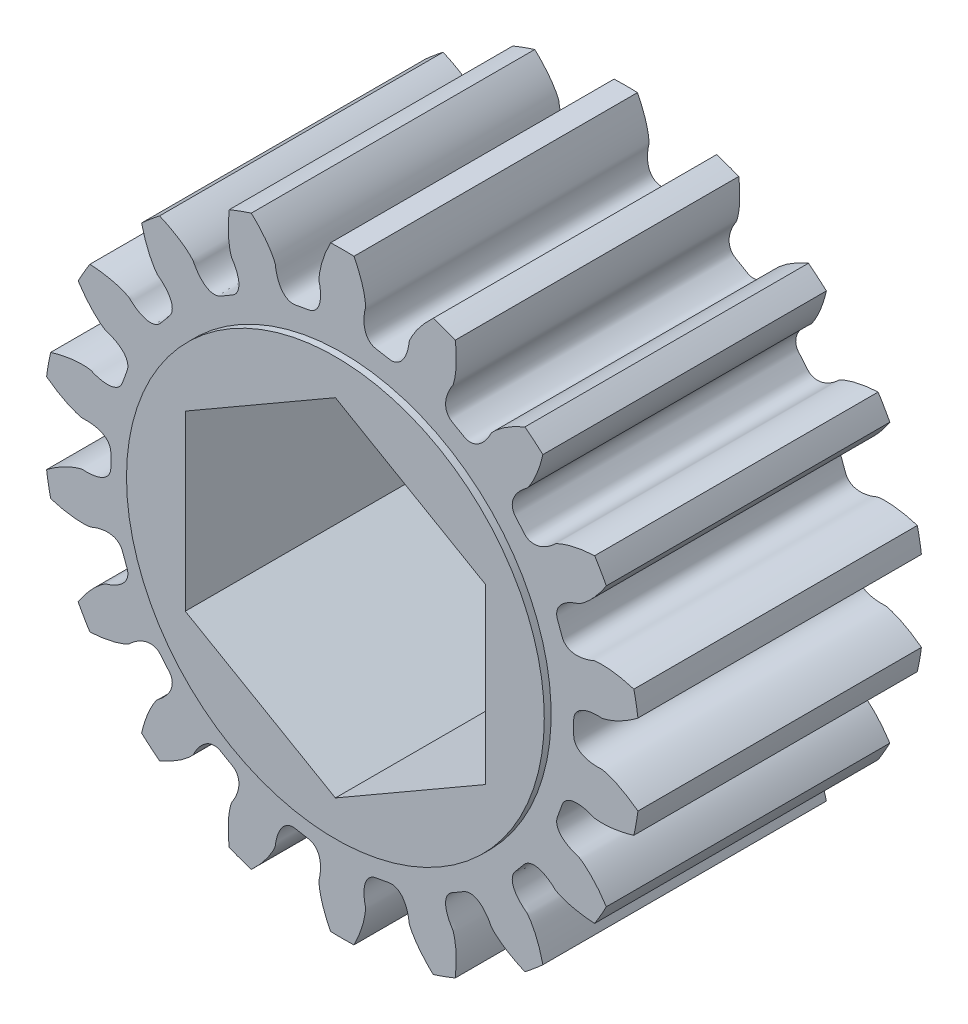
from build123d import *

# Parameters (mm, degrees)
BOSS_EXTRUDE1_DEPTH = 12.065
SKETCH2_R           = 8.89
BOSS_EXTRUDE2_DEPTH = 0.2921
SKETCH3_R           = 8.89
BOSS_EXTRUDE3_DEPTH = 0.2921
CUT_EXTRUDE1_DEPTH  = 13.6492


with BuildPart() as part:
    # Sketch1 → Boss-Extrude1 (new body)
    with BuildSketch(Plane.XY.offset(6.0325)):
        with BuildLine():
            ThreePointArc((12.410970883, -2.694030306), (12.507058369, -2.205331838), (12.583910389, -1.713241638))
            add(Edge.make_bspline(
                [(12.583910389, -1.713241638), (12.454495513, -1.615266365), (12.281691884, -1.494600081), (12.063530587, -1.360821083), (11.945634884, -1.293014345), (11.833605036, -1.232708673), (11.727763905, -1.179517154), (11.628417021, -1.133040061), (11.535852234, -1.09286743), (11.450339429, -1.058575143), (11.372129731, -1.029740178), (11.301456539, -1.005894736), (11.238530851, -0.986673766), (11.183554417, -0.971362731), (11.126066888, -0.957744243), (11.037383924, -0.935500863), (10.935383555, -0.952855993), (10.832757273, -0.948980949), (10.755684694, -0.945835715), (10.681454151, -0.939599556), (10.609986165, -0.931080188), (10.541241018, -0.920104184), (10.475144099, -0.906715101), (10.411601978, -0.890856967), (10.350496087, -0.872438809), (10.291684118, -0.851296022), (10.23500406, -0.827170041), (10.180287123, -0.799673241), (10.127386898, -0.768246797), (10.076238411, -0.732113156), (10.026966573, -0.690238537), (9.98006979, -0.641341891), (9.936675165, -0.584030203), (9.898843597, -0.517153755), (9.869552788, -0.440522263), (9.854050846, -0.362318712), (9.847049326, -0.214546824), (9.861767648, -5e-09), (9.847049326, 0.214546814), (9.854050846, 0.362318702), (9.869552789, 0.440522252), (9.898843597, 0.517153744), (9.936675165, 0.584030193), (9.980069791, 0.641341881), (10.026966574, 0.690238527), (10.076238412, 0.732113146), (10.127386899, 0.768246787), (10.180287124, 0.79967323), (10.235004061, 0.82717003), (10.291684119, 0.851296011), (10.350496088, 0.872438798), (10.411601979, 0.890856956), (10.4751441, 0.90671509), (10.541241019, 0.920104174), (10.609986166, 0.931080178), (10.681454152, 0.939599545), (10.755684695, 0.945835704), (10.832757274, 0.948980938), (10.935383556, 0.952855982), (11.037383925, 0.935500852), (11.126066889, 0.957744232), (11.183554418, 0.97136272), (11.238530852, 0.986673755), (11.30145654, 1.005894724), (11.372129732, 1.029740166), (11.45033943, 1.058575132), (11.535852235, 1.092867418), (11.628417022, 1.133040049), (11.727763907, 1.179517142), (11.833605037, 1.23270866), (11.945634885, 1.293014333), (12.063530588, 1.360821071), (12.281691885, 1.494600068), (12.454495515, 1.615266353), (12.58391039, 1.713241625)],
                knots=[0, 0, 0, 0, 0.068568258, 0.088954796, 0.108105787, 0.12602123, 0.142701125, 0.158145472, 0.172354272, 0.185327523, 0.197065227, 0.207567384, 0.216833992, 0.224865053, 0.231660567, 0.241835881, 0.263155637, 0.274398239, 0.285253325, 0.295735543, 0.30586243, 0.315655123, 0.325139277, 0.334346238, 0.343314557, 0.352091904, 0.360737466, 0.369324816, 0.377945084, 0.386709838, 0.395752205, 0.405223204, 0.415278018, 0.42604547, 0.437577809, 0.44979349, 0.459544035, 0.500000005, 0.540455975, 0.550206519, 0.5624222, 0.573954539, 0.584721991, 0.594776805, 0.604247805, 0.613290172, 0.622054925, 0.630675194, 0.639262544, 0.647908106, 0.656685453, 0.665653771, 0.674860733, 0.684344886, 0.69413758, 0.704264467, 0.714746685, 0.725601771, 0.736844372, 0.758164128, 0.768339443, 0.775134956, 0.783166017, 0.792432626, 0.802934782, 0.814672486, 0.827645738, 0.841854537, 0.857298885, 0.87397878, 0.891894222, 0.911045213, 0.931431751, 1.000000005, 1.000000005, 1.000000005, 1.000000005], degree=3))
            ThreePointArc((12.58391039, 1.713241625), (12.507058371, 2.205331832), (12.410970883, 2.694030306))
            add(Edge.make_bspline(
                [(12.410970883, 2.694030306), (12.255851163, 2.741834452), (12.052198568, 2.796121347), (11.801438895, 2.847216926), (11.667461903, 2.870611712), (11.541562526, 2.888964043), (11.423911826, 2.902747921), (11.31466019, 2.912443467), (11.213937893, 2.91853437), (11.121853489, 2.921511477), (11.038498274, 2.921858189), (10.963931576, 2.92009392), (10.898226812, 2.91663387), (10.84132918, 2.912218489), (10.782650776, 2.905353789), (10.691708366, 2.895924368), (10.601795176, 2.8447297), (10.504032672, 2.813270795), (10.430532405, 2.789865973), (10.35864562, 2.770337704), (10.288573885, 2.7538998), (10.220220564, 2.740701645), (10.153530441, 2.730676791), (10.088396577, 2.723845877), (10.024676441, 2.720253838), (9.962180009, 2.720006681), (9.900666605, 2.723291966), (9.839845043, 2.730416211), (9.779386616, 2.741854465), (9.718964327, 2.758315169), (9.658341981, 2.780812478), (9.597549782, 2.810720651), (9.537170421, 2.849734185), (9.478747284, 2.899638332), (9.425013413, 2.961630333), (9.383699162, 3.029815656), (9.326578923, 3.166281147), (9.267030288, 3.372923173), (9.179820255, 3.569497273), (9.13585857, 3.710752086), (9.123678441, 3.789541362), (9.124993284, 3.871569456), (9.137670236, 3.94735192), (9.158846094, 4.016049126), (9.186191017, 4.078036588), (9.218169437, 4.13423782), (9.253874859, 4.185686149), (9.292836333, 4.233310288), (9.334848976, 4.277863123), (9.379859237, 4.319919851), (9.427893151, 4.359902449), (9.479014525, 4.398109302), (9.533300786, 4.434743759), (9.590832237, 4.46993186), (9.651677529, 4.503758155), (9.715921673, 4.536207233), (9.783542674, 4.567455646), (9.854891475, 4.596771573), (9.950003292, 4.63551318), (10.05178809, 4.654090873), (10.127515133, 4.705324173), (10.176877942, 4.737783259), (10.223302209, 4.770973973), (10.275859055, 4.810557629), (10.33411451, 4.85713667), (10.397745447, 4.910981967), (10.466372546, 4.972453278), (10.539615145, 5.041862224), (10.617074577, 5.119515041), (10.698340136, 5.205698517), (10.782988003, 5.300683777), (10.870582454, 5.404723974), (11.029831903, 5.605050669), (11.150943898, 5.777542208), (11.239044585, 5.913871343)],
                knots=[0, 0, 0, 0, 0.068568258, 0.088954796, 0.108105787, 0.12602123, 0.142701125, 0.158145472, 0.172354272, 0.185327523, 0.197065227, 0.207567384, 0.216833992, 0.224865053, 0.231660567, 0.241835881, 0.263155637, 0.274398239, 0.285253325, 0.295735543, 0.30586243, 0.315655123, 0.325139277, 0.334346238, 0.343314557, 0.352091904, 0.360737466, 0.369324816, 0.377945084, 0.386709838, 0.395752205, 0.405223204, 0.415278018, 0.42604547, 0.437577809, 0.44979349, 0.459544035, 0.500000005, 0.540455975, 0.550206519, 0.5624222, 0.573954539, 0.584721991, 0.594776805, 0.604247805, 0.613290172, 0.622054925, 0.630675194, 0.639262544, 0.647908106, 0.656685453, 0.665653771, 0.674860733, 0.684344886, 0.69413758, 0.704264467, 0.714746685, 0.725601771, 0.736844372, 0.758164128, 0.768339443, 0.775134956, 0.783166017, 0.792432626, 0.802934782, 0.814672486, 0.827645738, 0.841854537, 0.857298885, 0.87397878, 0.891894222, 0.911045213, 0.931431751, 1.000000005, 1.000000005, 1.000000005, 1.000000005], degree=3))
            ThreePointArc((11.239044585, 5.913871343), (10.998522549, 6.349999934), (10.741085127, 6.776362423))
            add(Edge.make_bspline(
                [(10.741085127, 6.776362423), (10.57897029, 6.768229557), (10.369032237, 6.749589262), (10.115919506, 6.711838541), (9.982020827, 6.687999619), (9.857437245, 6.662185046), (9.742167386, 6.634898745), (9.636188358, 6.606643318), (9.539457148, 6.57791784), (9.451907882, 6.549220684), (9.373461019, 6.521037324), (9.303994658, 6.493876141), (9.243435784, 6.468152405), (9.191479648, 6.444543168), (9.138687851, 6.418023263), (9.05645499, 6.378058371), (8.989473837, 6.299198996), (8.908366713, 6.23620055), (8.847303975, 6.189068639), (8.786431555, 6.146131341), (8.726207757, 6.106718819), (8.66649068, 6.070938398), (8.607251166, 6.03870875), (8.548381665, 6.010012697), (8.489732872, 5.984843715), (8.431089969, 5.963236424), (8.372162644, 5.945284759), (8.312572436, 5.931177161), (8.251847984, 5.921247604), (8.189439713, 5.916049966), (8.124778809, 5.916456458), (8.057423631, 5.92376879), (7.987342176, 5.939778563), (7.915374162, 5.966691232), (7.843678327, 6.006566591), (7.781534876, 6.05650953), (7.681185462, 6.165208873), (7.554552314, 6.339022027), (7.405369388, 6.49391367), (7.315746925, 6.611613994), (7.277353829, 6.681485846), (7.250534116, 6.759016743), (7.236527426, 6.834564738), (7.232930395, 6.906361566), (7.237425257, 6.97396324), (7.248253188, 7.037712387), (7.264208945, 7.098269976), (7.28453234, 7.156347637), (7.308773343, 7.212582777), (7.336684905, 7.26749759), (7.368147166, 7.321497509), (7.40311803, 7.374884747), (7.441600707, 7.42787687), (7.483627548, 7.480619784), (7.529234146, 7.533216419), (7.578505655, 7.58568137), (7.631361024, 7.638173018), (7.688380328, 7.690123705), (7.764505791, 7.759059064), (7.85379827, 7.811328837), (7.907435592, 7.885372565), (7.942719799, 7.932757203), (7.974992447, 7.979824307), (8.010841319, 8.034996277), (8.04965257, 8.098690797), (8.091029917, 8.171051887), (8.134493868, 8.252287874), (8.17958014, 8.342561393), (8.225809369, 8.442023858), (8.27269753, 8.550804293), (8.319753634, 8.669012516), (8.36648165, 8.796737388), (8.447611417, 9.039449425), (8.502423885, 9.242961193), (8.53858414, 9.401200885)],
                knots=[0, 0, 0, 0, 0.068568258, 0.088954796, 0.108105787, 0.12602123, 0.142701125, 0.158145472, 0.172354272, 0.185327523, 0.197065227, 0.207567384, 0.216833992, 0.224865053, 0.231660567, 0.241835881, 0.263155637, 0.274398239, 0.285253325, 0.295735543, 0.30586243, 0.315655123, 0.325139277, 0.334346238, 0.343314557, 0.352091904, 0.360737466, 0.369324816, 0.377945084, 0.386709838, 0.395752205, 0.405223204, 0.415278018, 0.42604547, 0.437577809, 0.44979349, 0.459544035, 0.500000005, 0.540455975, 0.550206519, 0.5624222, 0.573954539, 0.584721991, 0.594776805, 0.604247805, 0.613290172, 0.622054925, 0.630675194, 0.639262544, 0.647908106, 0.656685453, 0.665653771, 0.674860733, 0.684344886, 0.69413758, 0.704264467, 0.714746685, 0.725601771, 0.736844372, 0.758164128, 0.768339443, 0.775134956, 0.783166017, 0.792432626, 0.802934782, 0.814672486, 0.827645738, 0.841854537, 0.857298885, 0.87397878, 0.891894222, 0.911045213, 0.931431751, 1.000000005, 1.000000005, 1.000000005, 1.000000005], degree=3))
            ThreePointArc((8.53858414, 9.401200885), (8.163402594, 9.728764322), (7.775665989, 10.041365223))
            add(Edge.make_bspline(
                [(7.775665989, 10.041365223), (7.626109477, 9.978276289), (7.435207594, 9.888957098), (7.210270936, 9.766913371), (7.092600726, 9.698716067), (6.984359558, 9.631848209), (6.885373786, 9.56678286), (6.795450001, 9.503984481), (6.714377089, 9.443907339), (6.641922695, 9.386997221), (6.577846033, 9.333683118), (6.521858679, 9.28440106), (6.473749987, 9.2395163), (6.433002025, 9.199560829), (6.392464304, 9.156584413), (6.32885949, 9.090904403), (6.292889289, 8.993891927), (6.238220261, 8.906952482), (6.196960119, 8.841778287), (6.154444176, 8.780610831), (6.111332194, 8.722977423), (6.067454122, 8.668930382), (6.022810376, 8.618383312), (5.977305769, 8.571283288), (5.93080223, 8.527573113), (5.883086055, 8.487211847), (5.833852314, 8.450188467), (5.782680918, 8.41655061), (5.729014708, 8.386450893), (5.672147813, 8.360221825), (5.61124741, 8.338488471), (5.545453281, 8.322322988), (5.47412259, 8.313397984), (5.397290103, 8.31407311), (5.31627988, 8.327022271), (5.240802647, 8.352698971), (5.109327678, 8.42052142), (4.930883844, 8.54054127), (4.737721687, 8.635068239), (4.613248238, 8.715017677), (4.553272948, 8.767544528), (4.501553533, 8.831226859), (4.462552614, 8.897428182), (4.434616549, 8.963664873), (4.415719203, 9.028727002), (4.404090638, 9.092334975), (4.39837223, 9.154697685), (4.397606244, 9.216223845), (4.401151785, 9.277358502), (4.408598102, 9.338507863), (4.419693896, 9.400011916), (4.434296249, 9.462140249), (4.452333762, 9.525098407), (4.473786935, 9.58903456), (4.49865401, 9.654057605), (4.527010014, 9.720210381), (4.558724614, 9.787613996), (4.594537051, 9.855933424), (4.642494306, 9.946747914), (4.708524474, 10.02640526), (4.733602623, 10.114328649), (4.750552431, 10.170923554), (4.764780903, 10.22619006), (4.779597899, 10.290295789), (4.794283736, 10.363423289), (4.808416773, 10.445572357), (4.821475183, 10.536774762), (4.832967058, 10.637024535), (4.842390157, 10.746300007), (4.849245516, 10.864556874), (4.853034196, 10.991730405), (4.853259689, 11.127734447), (4.846484327, 11.383557171), (4.828386074, 11.593542647), (4.808244437, 11.754606853)],
                knots=[0, 0, 0, 0, 0.068568258, 0.088954796, 0.108105787, 0.12602123, 0.142701125, 0.158145472, 0.172354272, 0.185327523, 0.197065227, 0.207567384, 0.216833992, 0.224865053, 0.231660567, 0.241835881, 0.263155637, 0.274398239, 0.285253325, 0.295735543, 0.30586243, 0.315655123, 0.325139277, 0.334346238, 0.343314557, 0.352091904, 0.360737466, 0.369324816, 0.377945084, 0.386709838, 0.395752205, 0.405223204, 0.415278018, 0.42604547, 0.437577809, 0.44979349, 0.459544035, 0.500000005, 0.540455975, 0.550206519, 0.5624222, 0.573954539, 0.584721991, 0.594776805, 0.604247805, 0.613290172, 0.622054925, 0.630675194, 0.639262544, 0.647908106, 0.656685453, 0.665653771, 0.674860733, 0.684344886, 0.69413758, 0.704264467, 0.714746685, 0.725601771, 0.736844372, 0.758164128, 0.768339443, 0.775134956, 0.783166017, 0.792432626, 0.802934782, 0.814672486, 0.827645738, 0.841854537, 0.857298885, 0.87397878, 0.891894222, 0.911045213, 0.931431751, 1.000000005, 1.000000005, 1.000000005, 1.000000005], degree=3))
            ThreePointArc((4.808244437, 11.754606853), (4.343655813, 11.934096152), (3.872386782, 12.095231182))
            add(Edge.make_bspline(
                [(3.872386782, 12.095231182), (3.753427317, 11.984795637), (3.604587189, 11.835570763), (3.434957284, 11.643954305), (3.347708308, 11.53962422), (3.268865036, 11.439768327), (3.198102496, 11.344771771), (3.13508009, 11.255004851), (3.079444065, 11.170822235), (3.030823612, 11.092563355), (2.988845743, 11.020548977), (2.953090296, 10.955090188), (2.923234405, 10.896458169), (2.898609422, 10.844975684), (2.875215224, 10.790726345), (2.837910136, 10.707253197), (2.837289425, 10.603788756), (2.815652384, 10.503394492), (2.799171421, 10.428038982), (2.780140005, 10.356019066), (2.75933978, 10.287116212), (2.736593057, 10.221321422), (2.711929774, 10.158553653), (2.685278587, 10.098730616), (2.656529316, 10.04175134), (2.625495144, 9.987504263), (2.591893302, 9.935874735), (2.555312744, 9.886763841), (2.515177711, 9.840124434), (2.47071118, 9.796027549), (2.420916765, 9.754775711), (2.364619428, 9.717082209), (2.300643036, 9.684298916), (2.228213209, 9.658655068), (2.147659626, 9.643116171), (2.067952278, 9.641429642), (1.921209576, 9.66019481), (1.712478015, 9.711945192), (1.498634835, 9.734706138), (1.354323736, 9.767261608), (1.280000156, 9.796107945), (1.209619164, 9.83826068), (1.150328102, 9.887130474), (1.101422505, 9.939817908), (1.06141225, 9.994493037), (1.028729765, 10.050287777), (1.002026917, 10.106933744), (0.980263939, 10.16448744), (0.962686374, 10.223147873), (0.948769309, 10.283156266), (0.93816032, 10.344746156), (0.930632902, 10.408121991), (0.926049662, 10.4734525), (0.924341599, 10.540870249), (0.925469814, 10.610476965), (0.92949016, 10.682338565), (0.936238741, 10.756524276), (0.946524804, 10.832972114), (0.960529497, 10.934712167), (0.995333141, 11.032149235), (0.988827324, 11.123347427), (0.985398336, 11.182326417), (0.979866467, 11.239126369), (0.971864438, 11.30443376), (0.960653533, 11.378173985), (0.945837607, 11.460202641), (0.92691544, 11.550371108), (0.903426828, 11.648505532), (0.874907232, 11.754413776), (0.840902932, 11.867883553), (0.800967217, 11.988683386), (0.754662989, 12.116562504), (0.660799707, 12.35463992), (0.571973649, 12.545771754), (0.497959499, 12.690233755)],
                knots=[0, 0, 0, 0, 0.068568258, 0.088954796, 0.108105787, 0.12602123, 0.142701125, 0.158145472, 0.172354272, 0.185327523, 0.197065227, 0.207567384, 0.216833992, 0.224865053, 0.231660567, 0.241835881, 0.263155637, 0.274398239, 0.285253325, 0.295735543, 0.30586243, 0.315655123, 0.325139277, 0.334346238, 0.343314557, 0.352091904, 0.360737466, 0.369324816, 0.377945084, 0.386709838, 0.395752205, 0.405223204, 0.415278018, 0.42604547, 0.437577809, 0.44979349, 0.459544035, 0.500000005, 0.540455975, 0.550206519, 0.5624222, 0.573954539, 0.584721991, 0.594776805, 0.604247805, 0.613290172, 0.622054925, 0.630675194, 0.639262544, 0.647908106, 0.656685453, 0.665653771, 0.674860733, 0.684344886, 0.69413758, 0.704264467, 0.714746685, 0.725601771, 0.736844372, 0.758164128, 0.768339443, 0.775134956, 0.783166017, 0.792432626, 0.802934782, 0.814672486, 0.827645738, 0.841854537, 0.857298885, 0.87397878, 0.891894222, 0.911045213, 0.931431751, 1.000000005, 1.000000005, 1.000000005, 1.000000005], degree=3))
            ThreePointArc((0.497959499, 12.690233755), (4.2e-08, 12.699999857), (-0.497959416, 12.690233754))
            add(Edge.make_bspline(
                [(-0.497959416, 12.690233754), (-0.571973566, 12.545771754), (-0.660799623, 12.354639919), (-0.754662905, 12.116562503), (-0.800967133, 11.988683385), (-0.840902847, 11.867883552), (-0.874907148, 11.754413776), (-0.903426744, 11.648505531), (-0.926915355, 11.550371107), (-0.945837523, 11.46020264), (-0.960653449, 11.378173984), (-0.971864354, 11.304433759), (-0.979866382, 11.239126368), (-0.985398251, 11.182326416), (-0.988827239, 11.123347426), (-0.995333057, 11.032149233), (-0.960529412, 10.934712166), (-0.946524718, 10.832972113), (-0.936238656, 10.756524275), (-0.929490075, 10.682338564), (-0.925469729, 10.610476964), (-0.924341513, 10.540870248), (-0.926049577, 10.473452499), (-0.930632816, 10.40812199), (-0.938160235, 10.344746155), (-0.948769224, 10.283156265), (-0.962686288, 10.223147872), (-0.980263854, 10.164487439), (-1.002026831, 10.106933743), (-1.028729679, 10.050287776), (-1.061412164, 9.994493036), (-1.101422419, 9.939817907), (-1.150328016, 9.887130473), (-1.209619078, 9.838260679), (-1.28000007, 9.796107944), (-1.354323649, 9.767261607), (-1.498634749, 9.734706137), (-1.712477929, 9.71194519), (-1.92120949, 9.660194808), (-2.067952192, 9.64142964), (-2.147659539, 9.643116169), (-2.228213122, 9.658655066), (-2.30064295, 9.684298913), (-2.364619342, 9.717082207), (-2.420916679, 9.754775709), (-2.470711094, 9.796027546), (-2.515177625, 9.840124431), (-2.555312658, 9.886763838), (-2.591893216, 9.935874733), (-2.625495058, 9.987504261), (-2.65652923, 10.041751337), (-2.685278501, 10.098730613), (-2.711929688, 10.158553651), (-2.736592971, 10.221321419), (-2.759339694, 10.287116209), (-2.78013992, 10.356019063), (-2.799171336, 10.42803898), (-2.815652299, 10.503394489), (-2.837289339, 10.603788753), (-2.837910051, 10.707253194), (-2.875215139, 10.790726342), (-2.898609336, 10.844975681), (-2.92323432, 10.896458166), (-2.953090211, 10.955090185), (-2.988845658, 11.020548974), (-3.030823527, 11.092563352), (-3.07944398, 11.170822232), (-3.135080005, 11.255004848), (-3.198102412, 11.344771768), (-3.268864951, 11.439768323), (-3.347708224, 11.539624216), (-3.434957199, 11.643954302), (-3.604587105, 11.835570759), (-3.753427233, 11.984795633), (-3.872386698, 12.095231178)],
                knots=[0, 0, 0, 0, 0.068568258, 0.088954796, 0.108105787, 0.12602123, 0.142701125, 0.158145472, 0.172354272, 0.185327523, 0.197065227, 0.207567384, 0.216833992, 0.224865053, 0.231660567, 0.241835881, 0.263155637, 0.274398239, 0.285253325, 0.295735543, 0.30586243, 0.315655123, 0.325139277, 0.334346238, 0.343314557, 0.352091904, 0.360737466, 0.369324816, 0.377945084, 0.386709838, 0.395752205, 0.405223204, 0.415278018, 0.42604547, 0.437577809, 0.44979349, 0.459544035, 0.500000005, 0.540455975, 0.550206519, 0.5624222, 0.573954539, 0.584721991, 0.594776805, 0.604247805, 0.613290172, 0.622054925, 0.630675194, 0.639262544, 0.647908106, 0.656685453, 0.665653771, 0.674860733, 0.684344886, 0.69413758, 0.704264467, 0.714746685, 0.725601771, 0.736844372, 0.758164128, 0.768339443, 0.775134956, 0.783166017, 0.792432626, 0.802934782, 0.814672486, 0.827645738, 0.841854537, 0.857298885, 0.87397878, 0.891894222, 0.911045213, 0.931431751, 1.000000005, 1.000000005, 1.000000005, 1.000000005], degree=3))
            ThreePointArc((-3.872386698, 12.095231178), (-4.343655729, 11.934096147), (-4.808244353, 11.754606848))
            add(Edge.make_bspline(
                [(-4.808244353, 11.754606848), (-4.82838599, 11.593542642), (-4.846484243, 11.383557166), (-4.853259604, 11.127734442), (-4.853034111, 10.9917304), (-4.849245431, 10.864556869), (-4.842390072, 10.746300002), (-4.832966973, 10.63702453), (-4.821475098, 10.536774757), (-4.808416687, 10.445572352), (-4.794283651, 10.363423284), (-4.779597813, 10.290295784), (-4.764780817, 10.226190055), (-4.750552345, 10.170923549), (-4.733602538, 10.114328644), (-4.708524388, 10.026405255), (-4.64249422, 9.946747909), (-4.594536965, 9.855933419), (-4.558724527, 9.787613991), (-4.527009928, 9.720210376), (-4.498653924, 9.6540576), (-4.473786849, 9.589034555), (-4.452333676, 9.525098402), (-4.434296162, 9.462140244), (-4.419693809, 9.400011911), (-4.408598015, 9.338507859), (-4.401151699, 9.277358498), (-4.397606157, 9.21622384), (-4.398372143, 9.15469768), (-4.404090551, 9.092334971), (-4.415719116, 9.028726997), (-4.434616462, 8.963664869), (-4.462552527, 8.897428177), (-4.501553446, 8.831226854), (-4.553272861, 8.767544524), (-4.613248151, 8.715017672), (-4.7377216, 8.635068234), (-4.930883756, 8.540541265), (-5.109327591, 8.420521415), (-5.240802559, 8.352698965), (-5.316279792, 8.327022266), (-5.397290015, 8.314073104), (-5.474122503, 8.313397978), (-5.545453193, 8.322322982), (-5.611247322, 8.338488465), (-5.672147725, 8.360221819), (-5.72901462, 8.386450887), (-5.78268083, 8.416550604), (-5.833852226, 8.450188461), (-5.883085968, 8.487211841), (-5.930802143, 8.527573107), (-5.977305681, 8.571283282), (-6.022810289, 8.618383306), (-6.067454035, 8.668930375), (-6.111332106, 8.722977417), (-6.154444089, 8.780610824), (-6.196960032, 8.84177828), (-6.238220174, 8.906952475), (-6.292889201, 8.993891921), (-6.328859403, 9.090904397), (-6.392464217, 9.156584406), (-6.433001938, 9.199560823), (-6.4737499, 9.239516293), (-6.521858592, 9.284401053), (-6.577845946, 9.333683111), (-6.641922608, 9.386997214), (-6.714377002, 9.443907332), (-6.795449914, 9.503984474), (-6.8853737, 9.566782853), (-6.984359472, 9.631848201), (-7.09260064, 9.69871606), (-7.210270849, 9.766913364), (-7.435207508, 9.88895709), (-7.626109391, 9.978276281), (-7.775665903, 10.041365215)],
                knots=[0, 0, 0, 0, 0.068568258, 0.088954796, 0.108105787, 0.12602123, 0.142701125, 0.158145472, 0.172354272, 0.185327523, 0.197065227, 0.207567384, 0.216833992, 0.224865053, 0.231660567, 0.241835881, 0.263155637, 0.274398239, 0.285253325, 0.295735543, 0.30586243, 0.315655123, 0.325139277, 0.334346238, 0.343314557, 0.352091904, 0.360737466, 0.369324816, 0.377945084, 0.386709838, 0.395752205, 0.405223204, 0.415278018, 0.42604547, 0.437577809, 0.44979349, 0.459544035, 0.500000005, 0.540455975, 0.550206519, 0.5624222, 0.573954539, 0.584721991, 0.594776805, 0.604247805, 0.613290172, 0.622054925, 0.630675194, 0.639262544, 0.647908106, 0.656685453, 0.665653771, 0.674860733, 0.684344886, 0.69413758, 0.704264467, 0.714746685, 0.725601771, 0.736844372, 0.758164128, 0.768339443, 0.775134956, 0.783166017, 0.792432626, 0.802934782, 0.814672486, 0.827645738, 0.841854537, 0.857298885, 0.87397878, 0.891894222, 0.911045213, 0.931431751, 1.000000005, 1.000000005, 1.000000005, 1.000000005], degree=3))
            ThreePointArc((-7.775665903, 10.041365215), (-8.163402508, 9.728764314), (-8.538584053, 9.401200876))
            add(Edge.make_bspline(
                [(-8.538584053, 9.401200876), (-8.502423798, 9.242961184), (-8.44761133, 9.039449416), (-8.366481563, 8.79673738), (-8.319753546, 8.669012508), (-8.272697442, 8.550804284), (-8.225809282, 8.44202385), (-8.179580052, 8.342561384), (-8.13449378, 8.252287866), (-8.091029829, 8.171051878), (-8.049652482, 8.098690788), (-8.010841231, 8.034996268), (-7.974992359, 7.979824299), (-7.942719711, 7.932757195), (-7.907435504, 7.885372557), (-7.853798181, 7.811328829), (-7.764505703, 7.759059056), (-7.68838024, 7.690123697), (-7.631360936, 7.63817301), (-7.578505567, 7.585681362), (-7.529234057, 7.533216411), (-7.483627459, 7.480619776), (-7.441600618, 7.427876863), (-7.403117941, 7.374884739), (-7.368147077, 7.321497502), (-7.336684816, 7.267497582), (-7.308773254, 7.21258277), (-7.284532251, 7.15634763), (-7.264208856, 7.098269968), (-7.248253099, 7.03771238), (-7.237425168, 6.973963233), (-7.232930305, 6.906361558), (-7.236527337, 6.834564731), (-7.250534027, 6.759016736), (-7.277353739, 6.681485838), (-7.315746836, 6.611613986), (-7.405369299, 6.493913663), (-7.554552225, 6.339022019), (-7.681185372, 6.165208865), (-7.781534786, 6.056509522), (-7.843678237, 6.006566583), (-7.915374072, 5.966691223), (-7.987342086, 5.939778555), (-8.057423541, 5.923768782), (-8.124778719, 5.916456449), (-8.189439623, 5.916049957), (-8.251847894, 5.921247596), (-8.312572346, 5.931177152), (-8.372162554, 5.94528475), (-8.431089879, 5.963236416), (-8.489732782, 5.984843706), (-8.548381574, 6.010012688), (-8.607251076, 6.038708741), (-8.66649059, 6.070938389), (-8.726207667, 6.10671881), (-8.786431465, 6.146131332), (-8.847303885, 6.18906863), (-8.908366623, 6.236200541), (-8.989473747, 6.299198987), (-9.056454901, 6.378058361), (-9.138687761, 6.418023254), (-9.191479559, 6.444543158), (-9.243435694, 6.468152395), (-9.303994569, 6.493876131), (-9.373460929, 6.521037315), (-9.451907792, 6.549220675), (-9.539457058, 6.57791783), (-9.636188269, 6.606643308), (-9.742167297, 6.634898735), (-9.857437156, 6.662185035), (-9.982020738, 6.687999609), (-10.115919417, 6.71183853), (-10.369032148, 6.749589251), (-10.578970201, 6.768229546), (-10.741085038, 6.776362412)],
                knots=[0, 0, 0, 0, 0.068568258, 0.088954796, 0.108105787, 0.12602123, 0.142701125, 0.158145472, 0.172354272, 0.185327523, 0.197065227, 0.207567384, 0.216833992, 0.224865053, 0.231660567, 0.241835881, 0.263155637, 0.274398239, 0.285253325, 0.295735543, 0.30586243, 0.315655123, 0.325139277, 0.334346238, 0.343314557, 0.352091904, 0.360737466, 0.369324816, 0.377945084, 0.386709838, 0.395752205, 0.405223204, 0.415278018, 0.42604547, 0.437577809, 0.44979349, 0.459544035, 0.500000005, 0.540455975, 0.550206519, 0.5624222, 0.573954539, 0.584721991, 0.594776805, 0.604247805, 0.613290172, 0.622054925, 0.630675194, 0.639262544, 0.647908106, 0.656685453, 0.665653771, 0.674860733, 0.684344886, 0.69413758, 0.704264467, 0.714746685, 0.725601771, 0.736844372, 0.758164128, 0.768339443, 0.775134956, 0.783166017, 0.792432626, 0.802934782, 0.814672486, 0.827645738, 0.841854537, 0.857298885, 0.87397878, 0.891894222, 0.911045213, 0.931431751, 1.000000005, 1.000000005, 1.000000005, 1.000000005], degree=3))
            ThreePointArc((-10.741085038, 6.776362412), (-10.998522459, 6.349999923), (-11.239044495, 5.913871331))
            add(Edge.make_bspline(
                [(-11.239044495, 5.913871331), (-11.150943808, 5.777542197), (-11.029831812, 5.605050658), (-10.870582363, 5.404723963), (-10.782987912, 5.300683766), (-10.698340045, 5.205698506), (-10.617074486, 5.11951503), (-10.539615054, 5.041862213), (-10.466372455, 4.972453267), (-10.397745356, 4.910981956), (-10.334114419, 4.85713666), (-10.275858964, 4.810557619), (-10.223302118, 4.770973963), (-10.176877851, 4.737783248), (-10.127515041, 4.705324163), (-10.051787999, 4.654090863), (-9.950003201, 4.635513169), (-9.854891383, 4.596771563), (-9.783542583, 4.567455636), (-9.715921582, 4.536207223), (-9.651677437, 4.503758145), (-9.590832145, 4.46993185), (-9.533300694, 4.434743749), (-9.479014433, 4.398109293), (-9.427893059, 4.35990244), (-9.379859145, 4.319919841), (-9.334848884, 4.277863113), (-9.292836241, 4.233310278), (-9.253874767, 4.185686139), (-9.218169345, 4.13423781), (-9.186190925, 4.078036578), (-9.158846002, 4.016049116), (-9.137670144, 3.94735191), (-9.124993192, 3.871569447), (-9.123678349, 3.789541353), (-9.135858477, 3.710752077), (-9.179820163, 3.569497263), (-9.267030195, 3.372923163), (-9.32657883, 3.166281138), (-9.383699069, 3.029815646), (-9.42501332, 2.961630323), (-9.47874719, 2.899638322), (-9.537170328, 2.849734175), (-9.597549689, 2.810720641), (-9.658341887, 2.780812468), (-9.718964234, 2.758315159), (-9.779386522, 2.741854455), (-9.83984495, 2.730416201), (-9.900666511, 2.723291955), (-9.962179915, 2.720006671), (-10.024676347, 2.720253828), (-10.088396483, 2.723845866), (-10.153530347, 2.73067678), (-10.220220471, 2.740701635), (-10.288573792, 2.75389979), (-10.358645527, 2.770337694), (-10.430532312, 2.789865962), (-10.504032579, 2.813270784), (-10.601795082, 2.844729689), (-10.691708273, 2.895924358), (-10.782650683, 2.905353778), (-10.841329087, 2.912218478), (-10.898226719, 2.916633859), (-10.963931482, 2.920093908), (-11.03849818, 2.921858178), (-11.121853396, 2.921511465), (-11.2139378, 2.918534358), (-11.314660097, 2.912443455), (-11.423911733, 2.90274791), (-11.541562433, 2.888964031), (-11.667461809, 2.8706117), (-11.801438801, 2.847216914), (-12.052198474, 2.796121335), (-12.25585107, 2.74183444), (-12.41097079, 2.694030294)],
                knots=[0, 0, 0, 0, 0.068568258, 0.088954796, 0.108105787, 0.12602123, 0.142701125, 0.158145472, 0.172354272, 0.185327523, 0.197065227, 0.207567384, 0.216833992, 0.224865053, 0.231660567, 0.241835881, 0.263155637, 0.274398239, 0.285253325, 0.295735543, 0.30586243, 0.315655123, 0.325139277, 0.334346238, 0.343314557, 0.352091904, 0.360737466, 0.369324816, 0.377945084, 0.386709838, 0.395752205, 0.405223204, 0.415278018, 0.42604547, 0.437577809, 0.44979349, 0.459544035, 0.500000005, 0.540455975, 0.550206519, 0.5624222, 0.573954539, 0.584721991, 0.594776805, 0.604247805, 0.613290172, 0.622054925, 0.630675194, 0.639262544, 0.647908106, 0.656685453, 0.665653771, 0.674860733, 0.684344886, 0.69413758, 0.704264467, 0.714746685, 0.725601771, 0.736844372, 0.758164128, 0.768339443, 0.775134956, 0.783166017, 0.792432626, 0.802934782, 0.814672486, 0.827645738, 0.841854537, 0.857298885, 0.87397878, 0.891894222, 0.911045213, 0.931431751, 1.000000005, 1.000000005, 1.000000005, 1.000000005], degree=3))
            ThreePointArc((-12.41097079, 2.694030294), (-12.507058275, 2.205331828), (-12.583910293, 1.713241631))
            add(Edge.make_bspline(
                [(-12.583910293, 1.713241631), (-12.454495418, 1.615266359), (-12.281691788, 1.494600075), (-12.063530491, 1.360821077), (-11.945634789, 1.293014339), (-11.83360494, 1.232708667), (-11.72776381, 1.179517148), (-11.628416925, 1.133040055), (-11.535852138, 1.092867424), (-11.450339333, 1.058575137), (-11.372129635, 1.029740172), (-11.301456443, 1.00589473), (-11.238530755, 0.986673761), (-11.183554321, 0.971362725), (-11.126066792, 0.957744237), (-11.037383829, 0.935500858), (-10.93538346, 0.952855987), (-10.832757177, 0.948980943), (-10.755684598, 0.94583571), (-10.681454055, 0.939599551), (-10.609986069, 0.931080183), (-10.541240923, 0.920104179), (-10.475144003, 0.906715096), (-10.411601882, 0.890856962), (-10.350495991, 0.872438803), (-10.291684022, 0.851296017), (-10.235003964, 0.827170036), (-10.180287027, 0.799673236), (-10.127386802, 0.768246792), (-10.076238316, 0.732113151), (-10.026966477, 0.690238532), (-9.980069694, 0.641341886), (-9.936675069, 0.584030198), (-9.898843501, 0.51715375), (-9.869552692, 0.440522258), (-9.85405075, 0.362318707), (-9.84704923, 0.214546819), (-9.861767552, 0), (-9.84704923, -0.214546819), (-9.85405075, -0.362318707), (-9.869552692, -0.440522258), (-9.898843501, -0.51715375), (-9.936675069, -0.584030198), (-9.980069694, -0.641341886), (-10.026966477, -0.690238532), (-10.076238316, -0.732113151), (-10.127386802, -0.768246792), (-10.180287027, -0.799673236), (-10.235003964, -0.827170036), (-10.291684022, -0.851296017), (-10.350495991, -0.872438803), (-10.411601882, -0.890856962), (-10.475144003, -0.906715096), (-10.541240923, -0.920104179), (-10.609986069, -0.931080183), (-10.681454055, -0.939599551), (-10.755684598, -0.94583571), (-10.832757177, -0.948980943), (-10.93538346, -0.952855987), (-11.037383829, -0.935500858), (-11.126066792, -0.957744237), (-11.183554321, -0.971362725), (-11.238530755, -0.986673761), (-11.301456443, -1.00589473), (-11.372129635, -1.029740172), (-11.450339333, -1.058575137), (-11.535852138, -1.092867424), (-11.628416925, -1.133040055), (-11.72776381, -1.179517148), (-11.83360494, -1.232708667), (-11.945634789, -1.293014339), (-12.063530491, -1.360821077), (-12.281691788, -1.494600075), (-12.454495418, -1.615266359), (-12.583910293, -1.713241631)],
                knots=[0, 0, 0, 0, 0.068568258, 0.088954796, 0.108105787, 0.12602123, 0.142701125, 0.158145472, 0.172354272, 0.185327523, 0.197065227, 0.207567384, 0.216833992, 0.224865053, 0.231660567, 0.241835881, 0.263155637, 0.274398239, 0.285253325, 0.295735543, 0.30586243, 0.315655123, 0.325139277, 0.334346238, 0.343314557, 0.352091904, 0.360737466, 0.369324816, 0.377945084, 0.386709838, 0.395752205, 0.405223204, 0.415278018, 0.42604547, 0.437577809, 0.44979349, 0.459544035, 0.500000005, 0.540455975, 0.550206519, 0.5624222, 0.573954539, 0.584721991, 0.594776805, 0.604247805, 0.613290172, 0.622054925, 0.630675194, 0.639262544, 0.647908106, 0.656685453, 0.665653771, 0.674860733, 0.684344886, 0.69413758, 0.704264467, 0.714746685, 0.725601771, 0.736844372, 0.758164128, 0.768339443, 0.775134956, 0.783166017, 0.792432626, 0.802934782, 0.814672486, 0.827645738, 0.841854537, 0.857298885, 0.87397878, 0.891894222, 0.911045213, 0.931431751, 1.000000005, 1.000000005, 1.000000005, 1.000000005], degree=3))
            ThreePointArc((-12.583910293, -1.713241631), (-12.507058275, -2.205331828), (-12.41097079, -2.694030294))
            add(Edge.make_bspline(
                [(-12.41097079, -2.694030294), (-12.25585107, -2.74183444), (-12.052198474, -2.796121335), (-11.801438801, -2.847216914), (-11.667461809, -2.8706117), (-11.541562433, -2.888964031), (-11.423911733, -2.90274791), (-11.314660097, -2.912443455), (-11.2139378, -2.918534358), (-11.121853396, -2.921511465), (-11.03849818, -2.921858178), (-10.963931482, -2.920093908), (-10.898226719, -2.916633859), (-10.841329087, -2.912218478), (-10.782650683, -2.905353778), (-10.691708273, -2.895924358), (-10.601795082, -2.844729689), (-10.504032579, -2.813270784), (-10.430532312, -2.789865962), (-10.358645527, -2.770337694), (-10.288573792, -2.75389979), (-10.220220471, -2.740701635), (-10.153530347, -2.73067678), (-10.088396483, -2.723845866), (-10.024676347, -2.720253828), (-9.962179915, -2.720006671), (-9.900666511, -2.723291955), (-9.83984495, -2.730416201), (-9.779386522, -2.741854455), (-9.718964234, -2.758315159), (-9.658341887, -2.780812468), (-9.597549689, -2.810720641), (-9.537170328, -2.849734175), (-9.47874719, -2.899638322), (-9.42501332, -2.961630323), (-9.383699069, -3.029815646), (-9.32657883, -3.166281138), (-9.267030195, -3.372923163), (-9.179820163, -3.569497263), (-9.135858477, -3.710752077), (-9.123678349, -3.789541353), (-9.124993192, -3.871569447), (-9.137670144, -3.94735191), (-9.158846002, -4.016049116), (-9.186190925, -4.078036578), (-9.218169345, -4.13423781), (-9.253874767, -4.185686139), (-9.292836241, -4.233310278), (-9.334848884, -4.277863113), (-9.379859145, -4.319919841), (-9.427893059, -4.35990244), (-9.479014433, -4.398109293), (-9.533300694, -4.434743749), (-9.590832145, -4.46993185), (-9.651677437, -4.503758145), (-9.715921582, -4.536207223), (-9.783542583, -4.567455636), (-9.854891383, -4.596771563), (-9.950003201, -4.635513169), (-10.051787999, -4.654090863), (-10.127515041, -4.705324163), (-10.176877851, -4.737783248), (-10.223302118, -4.770973963), (-10.275858964, -4.810557619), (-10.334114419, -4.85713666), (-10.397745356, -4.910981956), (-10.466372455, -4.972453267), (-10.539615054, -5.041862213), (-10.617074486, -5.11951503), (-10.698340045, -5.205698506), (-10.782987912, -5.300683766), (-10.870582363, -5.404723963), (-11.029831812, -5.605050658), (-11.150943808, -5.777542197), (-11.239044495, -5.913871331)],
                knots=[0, 0, 0, 0, 0.068568258, 0.088954796, 0.108105787, 0.12602123, 0.142701125, 0.158145472, 0.172354272, 0.185327523, 0.197065227, 0.207567384, 0.216833992, 0.224865053, 0.231660567, 0.241835881, 0.263155637, 0.274398239, 0.285253325, 0.295735543, 0.30586243, 0.315655123, 0.325139277, 0.334346238, 0.343314557, 0.352091904, 0.360737466, 0.369324816, 0.377945084, 0.386709838, 0.395752205, 0.405223204, 0.415278018, 0.42604547, 0.437577809, 0.44979349, 0.459544035, 0.500000005, 0.540455975, 0.550206519, 0.5624222, 0.573954539, 0.584721991, 0.594776805, 0.604247805, 0.613290172, 0.622054925, 0.630675194, 0.639262544, 0.647908106, 0.656685453, 0.665653771, 0.674860733, 0.684344886, 0.69413758, 0.704264467, 0.714746685, 0.725601771, 0.736844372, 0.758164128, 0.768339443, 0.775134956, 0.783166017, 0.792432626, 0.802934782, 0.814672486, 0.827645738, 0.841854537, 0.857298885, 0.87397878, 0.891894222, 0.911045213, 0.931431751, 1.000000005, 1.000000005, 1.000000005, 1.000000005], degree=3))
            ThreePointArc((-11.239044495, -5.913871331), (-10.998522459, -6.349999923), (-10.741085038, -6.776362412))
            add(Edge.make_bspline(
                [(-10.741085038, -6.776362412), (-10.578970201, -6.768229546), (-10.369032148, -6.749589251), (-10.115919417, -6.71183853), (-9.982020738, -6.687999609), (-9.857437156, -6.662185035), (-9.742167297, -6.634898735), (-9.636188269, -6.606643308), (-9.539457058, -6.57791783), (-9.451907792, -6.549220675), (-9.373460929, -6.521037315), (-9.303994569, -6.493876131), (-9.243435694, -6.468152395), (-9.191479559, -6.444543158), (-9.138687761, -6.418023254), (-9.056454901, -6.378058361), (-8.989473747, -6.299198987), (-8.908366623, -6.236200541), (-8.847303885, -6.18906863), (-8.786431465, -6.146131332), (-8.726207667, -6.10671881), (-8.66649059, -6.070938389), (-8.607251076, -6.038708741), (-8.548381574, -6.010012688), (-8.489732782, -5.984843706), (-8.431089879, -5.963236416), (-8.372162554, -5.94528475), (-8.312572346, -5.931177152), (-8.251847894, -5.921247596), (-8.189439623, -5.916049957), (-8.124778719, -5.916456449), (-8.057423541, -5.923768782), (-7.987342086, -5.939778555), (-7.915374072, -5.966691223), (-7.843678237, -6.006566583), (-7.781534786, -6.056509522), (-7.681185372, -6.165208865), (-7.554552225, -6.339022019), (-7.405369299, -6.493913663), (-7.315746836, -6.611613986), (-7.277353739, -6.681485838), (-7.250534027, -6.759016736), (-7.236527337, -6.834564731), (-7.232930305, -6.906361558), (-7.237425168, -6.973963233), (-7.248253099, -7.03771238), (-7.264208856, -7.098269968), (-7.284532251, -7.15634763), (-7.308773254, -7.21258277), (-7.336684816, -7.267497582), (-7.368147077, -7.321497502), (-7.403117941, -7.374884739), (-7.441600618, -7.427876863), (-7.483627459, -7.480619776), (-7.529234057, -7.533216411), (-7.578505567, -7.585681362), (-7.631360936, -7.63817301), (-7.68838024, -7.690123697), (-7.764505703, -7.759059056), (-7.853798181, -7.811328829), (-7.907435504, -7.885372557), (-7.942719711, -7.932757195), (-7.974992359, -7.979824299), (-8.010841231, -8.034996268), (-8.049652482, -8.098690788), (-8.091029829, -8.171051878), (-8.13449378, -8.252287866), (-8.179580052, -8.342561384), (-8.225809282, -8.44202385), (-8.272697442, -8.550804284), (-8.319753546, -8.669012508), (-8.366481563, -8.79673738), (-8.44761133, -9.039449416), (-8.502423798, -9.242961184), (-8.538584053, -9.401200876)],
                knots=[0, 0, 0, 0, 0.068568258, 0.088954796, 0.108105787, 0.12602123, 0.142701125, 0.158145472, 0.172354272, 0.185327523, 0.197065227, 0.207567384, 0.216833992, 0.224865053, 0.231660567, 0.241835881, 0.263155637, 0.274398239, 0.285253325, 0.295735543, 0.30586243, 0.315655123, 0.325139277, 0.334346238, 0.343314557, 0.352091904, 0.360737466, 0.369324816, 0.377945084, 0.386709838, 0.395752205, 0.405223204, 0.415278018, 0.42604547, 0.437577809, 0.44979349, 0.459544035, 0.500000005, 0.540455975, 0.550206519, 0.5624222, 0.573954539, 0.584721991, 0.594776805, 0.604247805, 0.613290172, 0.622054925, 0.630675194, 0.639262544, 0.647908106, 0.656685453, 0.665653771, 0.674860733, 0.684344886, 0.69413758, 0.704264467, 0.714746685, 0.725601771, 0.736844372, 0.758164128, 0.768339443, 0.775134956, 0.783166017, 0.792432626, 0.802934782, 0.814672486, 0.827645738, 0.841854537, 0.857298885, 0.87397878, 0.891894222, 0.911045213, 0.931431751, 1.000000005, 1.000000005, 1.000000005, 1.000000005], degree=3))
            ThreePointArc((-8.538584053, -9.401200876), (-8.163402508, -9.728764314), (-7.775665903, -10.041365215))
            add(Edge.make_bspline(
                [(-7.775665903, -10.041365215), (-7.626109391, -9.978276281), (-7.435207508, -9.88895709), (-7.210270849, -9.766913364), (-7.09260064, -9.69871606), (-6.984359472, -9.631848201), (-6.8853737, -9.566782853), (-6.795449914, -9.503984474), (-6.714377002, -9.443907332), (-6.641922608, -9.386997214), (-6.577845946, -9.333683111), (-6.521858592, -9.284401053), (-6.4737499, -9.239516293), (-6.433001938, -9.199560823), (-6.392464217, -9.156584406), (-6.328859403, -9.090904397), (-6.292889201, -8.993891921), (-6.238220174, -8.906952475), (-6.196960032, -8.84177828), (-6.154444089, -8.780610824), (-6.111332106, -8.722977417), (-6.067454035, -8.668930375), (-6.022810289, -8.618383306), (-5.977305681, -8.571283282), (-5.930802143, -8.527573107), (-5.883085968, -8.487211841), (-5.833852226, -8.450188461), (-5.78268083, -8.416550604), (-5.72901462, -8.386450887), (-5.672147725, -8.360221819), (-5.611247322, -8.338488465), (-5.545453193, -8.322322982), (-5.474122503, -8.313397978), (-5.397290015, -8.314073104), (-5.316279792, -8.327022266), (-5.240802559, -8.352698965), (-5.109327591, -8.420521415), (-4.930883756, -8.540541265), (-4.7377216, -8.635068234), (-4.613248151, -8.715017672), (-4.553272861, -8.767544524), (-4.501553446, -8.831226854), (-4.462552527, -8.897428177), (-4.434616462, -8.963664869), (-4.415719116, -9.028726997), (-4.404090551, -9.092334971), (-4.398372143, -9.15469768), (-4.397606157, -9.21622384), (-4.401151699, -9.277358498), (-4.408598015, -9.338507859), (-4.419693809, -9.400011911), (-4.434296162, -9.462140244), (-4.452333676, -9.525098402), (-4.473786849, -9.589034555), (-4.498653924, -9.6540576), (-4.527009928, -9.720210376), (-4.558724527, -9.787613991), (-4.594536965, -9.855933419), (-4.64249422, -9.946747909), (-4.708524388, -10.026405255), (-4.733602538, -10.114328644), (-4.750552345, -10.170923549), (-4.764780817, -10.226190055), (-4.779597813, -10.290295784), (-4.794283651, -10.363423284), (-4.808416687, -10.445572352), (-4.821475098, -10.536774757), (-4.832966973, -10.63702453), (-4.842390072, -10.746300002), (-4.849245431, -10.864556869), (-4.853034111, -10.9917304), (-4.853259604, -11.127734442), (-4.846484243, -11.383557166), (-4.82838599, -11.593542642), (-4.808244353, -11.754606848)],
                knots=[0, 0, 0, 0, 0.068568258, 0.088954796, 0.108105787, 0.12602123, 0.142701125, 0.158145472, 0.172354272, 0.185327523, 0.197065227, 0.207567384, 0.216833992, 0.224865053, 0.231660567, 0.241835881, 0.263155637, 0.274398239, 0.285253325, 0.295735543, 0.30586243, 0.315655123, 0.325139277, 0.334346238, 0.343314557, 0.352091904, 0.360737466, 0.369324816, 0.377945084, 0.386709838, 0.395752205, 0.405223204, 0.415278018, 0.42604547, 0.437577809, 0.44979349, 0.459544035, 0.500000005, 0.540455975, 0.550206519, 0.5624222, 0.573954539, 0.584721991, 0.594776805, 0.604247805, 0.613290172, 0.622054925, 0.630675194, 0.639262544, 0.647908106, 0.656685453, 0.665653771, 0.674860733, 0.684344886, 0.69413758, 0.704264467, 0.714746685, 0.725601771, 0.736844372, 0.758164128, 0.768339443, 0.775134956, 0.783166017, 0.792432626, 0.802934782, 0.814672486, 0.827645738, 0.841854537, 0.857298885, 0.87397878, 0.891894222, 0.911045213, 0.931431751, 1.000000005, 1.000000005, 1.000000005, 1.000000005], degree=3))
            ThreePointArc((-4.808244353, -11.754606848), (-4.343655729, -11.934096147), (-3.872386698, -12.095231178))
            add(Edge.make_bspline(
                [(-3.872386698, -12.095231178), (-3.753427233, -11.984795633), (-3.604587105, -11.835570759), (-3.434957199, -11.643954302), (-3.347708224, -11.539624216), (-3.268864951, -11.439768323), (-3.198102412, -11.344771768), (-3.135080005, -11.255004848), (-3.07944398, -11.170822232), (-3.030823527, -11.092563352), (-2.988845658, -11.020548974), (-2.953090211, -10.955090185), (-2.92323432, -10.896458166), (-2.898609336, -10.844975681), (-2.875215139, -10.790726342), (-2.837910051, -10.707253194), (-2.837289339, -10.603788753), (-2.815652299, -10.503394489), (-2.799171336, -10.42803898), (-2.78013992, -10.356019063), (-2.759339694, -10.287116209), (-2.736592971, -10.221321419), (-2.711929688, -10.158553651), (-2.685278501, -10.098730613), (-2.65652923, -10.041751337), (-2.625495058, -9.987504261), (-2.591893216, -9.935874733), (-2.555312658, -9.886763838), (-2.515177625, -9.840124431), (-2.470711094, -9.796027546), (-2.420916679, -9.754775709), (-2.364619342, -9.717082207), (-2.30064295, -9.684298913), (-2.228213122, -9.658655066), (-2.147659539, -9.643116169), (-2.067952192, -9.64142964), (-1.92120949, -9.660194808), (-1.712477929, -9.71194519), (-1.498634749, -9.734706137), (-1.354323649, -9.767261607), (-1.28000007, -9.796107944), (-1.209619078, -9.838260679), (-1.150328016, -9.887130473), (-1.101422419, -9.939817907), (-1.061412164, -9.994493036), (-1.028729679, -10.050287776), (-1.002026831, -10.106933743), (-0.980263854, -10.164487439), (-0.962686288, -10.223147872), (-0.948769224, -10.283156265), (-0.938160235, -10.344746155), (-0.930632816, -10.40812199), (-0.926049577, -10.473452499), (-0.924341513, -10.540870248), (-0.925469729, -10.610476964), (-0.929490075, -10.682338564), (-0.936238656, -10.756524275), (-0.946524718, -10.832972113), (-0.960529412, -10.934712166), (-0.995333057, -11.032149233), (-0.988827239, -11.123347426), (-0.985398251, -11.182326416), (-0.979866382, -11.239126368), (-0.971864354, -11.304433759), (-0.960653449, -11.378173984), (-0.945837523, -11.46020264), (-0.926915355, -11.550371107), (-0.903426744, -11.648505531), (-0.874907148, -11.754413776), (-0.840902847, -11.867883552), (-0.800967133, -11.988683385), (-0.754662905, -12.116562503), (-0.660799623, -12.354639919), (-0.571973566, -12.545771754), (-0.497959416, -12.690233754)],
                knots=[0, 0, 0, 0, 0.068568258, 0.088954796, 0.108105787, 0.12602123, 0.142701125, 0.158145472, 0.172354272, 0.185327523, 0.197065227, 0.207567384, 0.216833992, 0.224865053, 0.231660567, 0.241835881, 0.263155637, 0.274398239, 0.285253325, 0.295735543, 0.30586243, 0.315655123, 0.325139277, 0.334346238, 0.343314557, 0.352091904, 0.360737466, 0.369324816, 0.377945084, 0.386709838, 0.395752205, 0.405223204, 0.415278018, 0.42604547, 0.437577809, 0.44979349, 0.459544035, 0.500000005, 0.540455975, 0.550206519, 0.5624222, 0.573954539, 0.584721991, 0.594776805, 0.604247805, 0.613290172, 0.622054925, 0.630675194, 0.639262544, 0.647908106, 0.656685453, 0.665653771, 0.674860733, 0.684344886, 0.69413758, 0.704264467, 0.714746685, 0.725601771, 0.736844372, 0.758164128, 0.768339443, 0.775134956, 0.783166017, 0.792432626, 0.802934782, 0.814672486, 0.827645738, 0.841854537, 0.857298885, 0.87397878, 0.891894222, 0.911045213, 0.931431751, 1.000000005, 1.000000005, 1.000000005, 1.000000005], degree=3))
            ThreePointArc((-0.497959416, -12.690233754), (4.2e-08, -12.699999857), (0.497959499, -12.690233755))
            add(Edge.make_bspline(
                [(0.497959499, -12.690233755), (0.571973649, -12.545771754), (0.660799707, -12.35463992), (0.754662989, -12.116562504), (0.800967217, -11.988683386), (0.840902932, -11.867883553), (0.874907232, -11.754413776), (0.903426828, -11.648505532), (0.92691544, -11.550371108), (0.945837607, -11.460202641), (0.960653533, -11.378173985), (0.971864438, -11.30443376), (0.979866467, -11.239126369), (0.985398336, -11.182326417), (0.988827324, -11.123347427), (0.995333141, -11.032149235), (0.960529497, -10.934712167), (0.946524804, -10.832972114), (0.936238741, -10.756524276), (0.92949016, -10.682338565), (0.925469814, -10.610476965), (0.924341599, -10.540870249), (0.926049662, -10.4734525), (0.930632902, -10.408121991), (0.93816032, -10.344746156), (0.948769309, -10.283156266), (0.962686374, -10.223147873), (0.980263939, -10.16448744), (1.002026917, -10.106933744), (1.028729765, -10.050287777), (1.06141225, -9.994493037), (1.101422505, -9.939817908), (1.150328102, -9.887130474), (1.209619164, -9.83826068), (1.280000156, -9.796107945), (1.354323736, -9.767261608), (1.498634835, -9.734706138), (1.712478015, -9.711945192), (1.921209576, -9.66019481), (2.067952278, -9.641429642), (2.147659626, -9.643116171), (2.228213209, -9.658655068), (2.300643036, -9.684298916), (2.364619428, -9.717082209), (2.420916765, -9.754775711), (2.47071118, -9.796027549), (2.515177711, -9.840124434), (2.555312744, -9.886763841), (2.591893302, -9.935874735), (2.625495144, -9.987504263), (2.656529316, -10.04175134), (2.685278587, -10.098730616), (2.711929774, -10.158553653), (2.736593057, -10.221321422), (2.75933978, -10.287116212), (2.780140005, -10.356019066), (2.799171421, -10.428038982), (2.815652384, -10.503394492), (2.837289425, -10.603788756), (2.837910136, -10.707253197), (2.875215224, -10.790726345), (2.898609422, -10.844975684), (2.923234405, -10.896458169), (2.953090296, -10.955090188), (2.988845743, -11.020548977), (3.030823612, -11.092563355), (3.079444065, -11.170822235), (3.13508009, -11.255004851), (3.198102496, -11.344771771), (3.268865036, -11.439768327), (3.347708308, -11.53962422), (3.434957284, -11.643954305), (3.604587189, -11.835570763), (3.753427317, -11.984795637), (3.872386782, -12.095231182)],
                knots=[0, 0, 0, 0, 0.068568258, 0.088954796, 0.108105787, 0.12602123, 0.142701125, 0.158145472, 0.172354272, 0.185327523, 0.197065227, 0.207567384, 0.216833992, 0.224865053, 0.231660567, 0.241835881, 0.263155637, 0.274398239, 0.285253325, 0.295735543, 0.30586243, 0.315655123, 0.325139277, 0.334346238, 0.343314557, 0.352091904, 0.360737466, 0.369324816, 0.377945084, 0.386709838, 0.395752205, 0.405223204, 0.415278018, 0.42604547, 0.437577809, 0.44979349, 0.459544035, 0.500000005, 0.540455975, 0.550206519, 0.5624222, 0.573954539, 0.584721991, 0.594776805, 0.604247805, 0.613290172, 0.622054925, 0.630675194, 0.639262544, 0.647908106, 0.656685453, 0.665653771, 0.674860733, 0.684344886, 0.69413758, 0.704264467, 0.714746685, 0.725601771, 0.736844372, 0.758164128, 0.768339443, 0.775134956, 0.783166017, 0.792432626, 0.802934782, 0.814672486, 0.827645738, 0.841854537, 0.857298885, 0.87397878, 0.891894222, 0.911045213, 0.931431751, 1.000000005, 1.000000005, 1.000000005, 1.000000005], degree=3))
            ThreePointArc((3.872386782, -12.095231182), (4.343655813, -11.934096152), (4.808244437, -11.754606853))
            add(Edge.make_bspline(
                [(4.808244437, -11.754606853), (4.828386074, -11.593542647), (4.846484327, -11.383557171), (4.853259689, -11.127734447), (4.853034196, -10.991730405), (4.849245516, -10.864556874), (4.842390157, -10.746300007), (4.832967058, -10.637024535), (4.821475183, -10.536774762), (4.808416773, -10.445572357), (4.794283736, -10.363423289), (4.779597899, -10.290295789), (4.764780903, -10.22619006), (4.750552431, -10.170923554), (4.733602623, -10.114328649), (4.708524474, -10.02640526), (4.642494306, -9.946747914), (4.594537051, -9.855933424), (4.558724614, -9.787613996), (4.527010014, -9.720210381), (4.49865401, -9.654057605), (4.473786935, -9.58903456), (4.452333762, -9.525098407), (4.434296249, -9.462140249), (4.419693896, -9.400011916), (4.408598102, -9.338507863), (4.401151785, -9.277358502), (4.397606244, -9.216223845), (4.39837223, -9.154697685), (4.404090638, -9.092334975), (4.415719203, -9.028727002), (4.434616549, -8.963664873), (4.462552614, -8.897428182), (4.501553533, -8.831226859), (4.553272948, -8.767544528), (4.613248238, -8.715017677), (4.737721687, -8.635068239), (4.930883844, -8.54054127), (5.109327678, -8.42052142), (5.240802647, -8.352698971), (5.31627988, -8.327022271), (5.397290103, -8.31407311), (5.47412259, -8.313397984), (5.545453281, -8.322322988), (5.61124741, -8.338488471), (5.672147813, -8.360221825), (5.729014708, -8.386450893), (5.782680918, -8.41655061), (5.833852314, -8.450188467), (5.883086055, -8.487211847), (5.93080223, -8.527573113), (5.977305769, -8.571283288), (6.022810376, -8.618383312), (6.067454122, -8.668930382), (6.111332194, -8.722977423), (6.154444176, -8.780610831), (6.196960119, -8.841778287), (6.238220261, -8.906952482), (6.292889289, -8.993891927), (6.32885949, -9.090904403), (6.392464304, -9.156584413), (6.433002025, -9.199560829), (6.473749987, -9.2395163), (6.521858679, -9.28440106), (6.577846033, -9.333683118), (6.641922695, -9.386997221), (6.714377089, -9.443907339), (6.795450001, -9.503984481), (6.885373786, -9.56678286), (6.984359558, -9.631848209), (7.092600726, -9.698716067), (7.210270936, -9.766913371), (7.435207594, -9.888957098), (7.626109477, -9.978276289), (7.775665989, -10.041365223)],
                knots=[0, 0, 0, 0, 0.068568258, 0.088954796, 0.108105787, 0.12602123, 0.142701125, 0.158145472, 0.172354272, 0.185327523, 0.197065227, 0.207567384, 0.216833992, 0.224865053, 0.231660567, 0.241835881, 0.263155637, 0.274398239, 0.285253325, 0.295735543, 0.30586243, 0.315655123, 0.325139277, 0.334346238, 0.343314557, 0.352091904, 0.360737466, 0.369324816, 0.377945084, 0.386709838, 0.395752205, 0.405223204, 0.415278018, 0.42604547, 0.437577809, 0.44979349, 0.459544035, 0.500000005, 0.540455975, 0.550206519, 0.5624222, 0.573954539, 0.584721991, 0.594776805, 0.604247805, 0.613290172, 0.622054925, 0.630675194, 0.639262544, 0.647908106, 0.656685453, 0.665653771, 0.674860733, 0.684344886, 0.69413758, 0.704264467, 0.714746685, 0.725601771, 0.736844372, 0.758164128, 0.768339443, 0.775134956, 0.783166017, 0.792432626, 0.802934782, 0.814672486, 0.827645738, 0.841854537, 0.857298885, 0.87397878, 0.891894222, 0.911045213, 0.931431751, 1.000000005, 1.000000005, 1.000000005, 1.000000005], degree=3))
            ThreePointArc((7.775665989, -10.041365223), (8.163402594, -9.728764322), (8.53858414, -9.401200885))
            add(Edge.make_bspline(
                [(8.53858414, -9.401200885), (8.502423885, -9.242961193), (8.447611417, -9.039449425), (8.36648165, -8.796737388), (8.319753634, -8.669012516), (8.27269753, -8.550804293), (8.225809369, -8.442023858), (8.17958014, -8.342561393), (8.134493868, -8.252287874), (8.091029917, -8.171051887), (8.04965257, -8.098690797), (8.010841319, -8.034996277), (7.974992447, -7.979824307), (7.942719799, -7.932757203), (7.907435592, -7.885372565), (7.85379827, -7.811328837), (7.764505791, -7.759059064), (7.688380328, -7.690123705), (7.631361024, -7.638173018), (7.578505655, -7.58568137), (7.529234146, -7.533216419), (7.483627548, -7.480619784), (7.441600707, -7.42787687), (7.40311803, -7.374884747), (7.368147166, -7.321497509), (7.336684905, -7.26749759), (7.308773343, -7.212582777), (7.28453234, -7.156347637), (7.264208945, -7.098269976), (7.248253188, -7.037712387), (7.237425257, -6.97396324), (7.232930395, -6.906361566), (7.236527426, -6.834564738), (7.250534116, -6.759016743), (7.277353829, -6.681485846), (7.315746925, -6.611613994), (7.405369388, -6.49391367), (7.554552314, -6.339022027), (7.681185462, -6.165208873), (7.781534876, -6.05650953), (7.843678327, -6.006566591), (7.915374162, -5.966691232), (7.987342176, -5.939778563), (8.057423631, -5.92376879), (8.124778809, -5.916456458), (8.189439713, -5.916049966), (8.251847984, -5.921247604), (8.312572436, -5.931177161), (8.372162644, -5.945284759), (8.431089969, -5.963236424), (8.489732872, -5.984843715), (8.548381665, -6.010012697), (8.607251166, -6.03870875), (8.66649068, -6.070938398), (8.726207757, -6.106718819), (8.786431555, -6.146131341), (8.847303975, -6.189068639), (8.908366713, -6.23620055), (8.989473837, -6.299198996), (9.05645499, -6.378058371), (9.138687851, -6.418023263), (9.191479648, -6.444543168), (9.243435784, -6.468152405), (9.303994658, -6.493876141), (9.373461019, -6.521037324), (9.451907882, -6.549220684), (9.539457148, -6.57791784), (9.636188358, -6.606643318), (9.742167386, -6.634898745), (9.857437245, -6.662185046), (9.982020827, -6.687999619), (10.115919506, -6.711838541), (10.369032237, -6.749589262), (10.57897029, -6.768229557), (10.741085127, -6.776362423)],
                knots=[0, 0, 0, 0, 0.068568258, 0.088954796, 0.108105787, 0.12602123, 0.142701125, 0.158145472, 0.172354272, 0.185327523, 0.197065227, 0.207567384, 0.216833992, 0.224865053, 0.231660567, 0.241835881, 0.263155637, 0.274398239, 0.285253325, 0.295735543, 0.30586243, 0.315655123, 0.325139277, 0.334346238, 0.343314557, 0.352091904, 0.360737466, 0.369324816, 0.377945084, 0.386709838, 0.395752205, 0.405223204, 0.415278018, 0.42604547, 0.437577809, 0.44979349, 0.459544035, 0.500000005, 0.540455975, 0.550206519, 0.5624222, 0.573954539, 0.584721991, 0.594776805, 0.604247805, 0.613290172, 0.622054925, 0.630675194, 0.639262544, 0.647908106, 0.656685453, 0.665653771, 0.674860733, 0.684344886, 0.69413758, 0.704264467, 0.714746685, 0.725601771, 0.736844372, 0.758164128, 0.768339443, 0.775134956, 0.783166017, 0.792432626, 0.802934782, 0.814672486, 0.827645738, 0.841854537, 0.857298885, 0.87397878, 0.891894222, 0.911045213, 0.931431751, 1.000000005, 1.000000005, 1.000000005, 1.000000005], degree=3))
            ThreePointArc((10.741085127, -6.776362423), (10.998522549, -6.349999934), (11.239044585, -5.913871343))
            add(Edge.make_bspline(
                [(11.239044585, -5.913871343), (11.150943898, -5.777542208), (11.029831903, -5.605050669), (10.870582454, -5.404723974), (10.782988003, -5.300683777), (10.698340136, -5.205698517), (10.617074577, -5.119515041), (10.539615145, -5.041862224), (10.466372546, -4.972453278), (10.397745447, -4.910981967), (10.33411451, -4.85713667), (10.275859055, -4.810557629), (10.223302209, -4.770973973), (10.176877942, -4.737783259), (10.127515133, -4.705324173), (10.05178809, -4.654090873), (9.950003292, -4.63551318), (9.854891475, -4.596771573), (9.783542674, -4.567455646), (9.715921673, -4.536207233), (9.651677529, -4.503758155), (9.590832237, -4.46993186), (9.533300786, -4.434743759), (9.479014525, -4.398109302), (9.427893151, -4.359902449), (9.379859237, -4.319919851), (9.334848976, -4.277863123), (9.292836333, -4.233310288), (9.253874859, -4.185686149), (9.218169437, -4.13423782), (9.186191017, -4.078036588), (9.158846094, -4.016049126), (9.137670236, -3.94735192), (9.124993284, -3.871569456), (9.123678441, -3.789541362), (9.13585857, -3.710752086), (9.179820255, -3.569497273), (9.267030288, -3.372923173), (9.326578923, -3.166281147), (9.383699162, -3.029815656), (9.425013413, -2.961630333), (9.478747284, -2.899638332), (9.537170421, -2.849734185), (9.597549782, -2.810720651), (9.658341981, -2.780812478), (9.718964327, -2.758315169), (9.779386616, -2.741854465), (9.839845043, -2.730416211), (9.900666605, -2.723291966), (9.962180009, -2.720006681), (10.024676441, -2.720253838), (10.088396577, -2.723845877), (10.153530441, -2.730676791), (10.220220564, -2.740701645), (10.288573885, -2.7538998), (10.35864562, -2.770337704), (10.430532405, -2.789865973), (10.504032672, -2.813270795), (10.601795176, -2.8447297), (10.691708366, -2.895924368), (10.782650776, -2.905353789), (10.84132918, -2.912218489), (10.898226812, -2.91663387), (10.963931576, -2.92009392), (11.038498274, -2.921858189), (11.121853489, -2.921511477), (11.213937893, -2.91853437), (11.31466019, -2.912443467), (11.423911826, -2.902747921), (11.541562526, -2.888964043), (11.667461903, -2.870611712), (11.801438895, -2.847216926), (12.052198568, -2.796121347), (12.255851163, -2.741834452), (12.410970883, -2.694030306)],
                knots=[0, 0, 0, 0, 0.068568258, 0.088954796, 0.108105787, 0.12602123, 0.142701125, 0.158145472, 0.172354272, 0.185327523, 0.197065227, 0.207567384, 0.216833992, 0.224865053, 0.231660567, 0.241835881, 0.263155637, 0.274398239, 0.285253325, 0.295735543, 0.30586243, 0.315655123, 0.325139277, 0.334346238, 0.343314557, 0.352091904, 0.360737466, 0.369324816, 0.377945084, 0.386709838, 0.395752205, 0.405223204, 0.415278018, 0.42604547, 0.437577809, 0.44979349, 0.459544035, 0.500000005, 0.540455975, 0.550206519, 0.5624222, 0.573954539, 0.584721991, 0.594776805, 0.604247805, 0.613290172, 0.622054925, 0.630675194, 0.639262544, 0.647908106, 0.656685453, 0.665653771, 0.674860733, 0.684344886, 0.69413758, 0.704264467, 0.714746685, 0.725601771, 0.736844372, 0.758164128, 0.768339443, 0.775134956, 0.783166017, 0.792432626, 0.802934782, 0.814672486, 0.827645738, 0.841854537, 0.857298885, 0.87397878, 0.891894222, 0.911045213, 0.931431751, 1.000000005, 1.000000005, 1.000000005, 1.000000005], degree=3))
        make_face()
    extrude(amount=-BOSS_EXTRUDE1_DEPTH)

    # Sketch2 → Boss-Extrude2 (add)
    with BuildSketch(Plane.XY.offset(6.0325)):
        Circle(SKETCH2_R)
    extrude(amount=BOSS_EXTRUDE2_DEPTH)

    # Sketch3 → Boss-Extrude3 (add)
    with BuildSketch(Plane(origin=(0, 0, -6.0325), x_dir=(-1, 0, 0), z_dir=(0, 0, -1))):
        Circle(SKETCH3_R)
    extrude(amount=BOSS_EXTRUDE3_DEPTH)

    # Sketch4 → Cut-Extrude1 (cut, through all)
    with BuildSketch(Plane(origin=(0, 0, -6.3246), x_dir=(-1, 0, 0), z_dir=(0, 0, -1))):
        Polygon((0, -7.376342509), (6.3881, -3.688171255), (6.3881, 3.688171255), (0, 7.376342509), (-6.3881, 3.688171255), (-6.3881, -3.688171255), align=None)
    extrude(amount=-CUT_EXTRUDE1_DEPTH, mode=Mode.SUBTRACT)


solid = part.part
